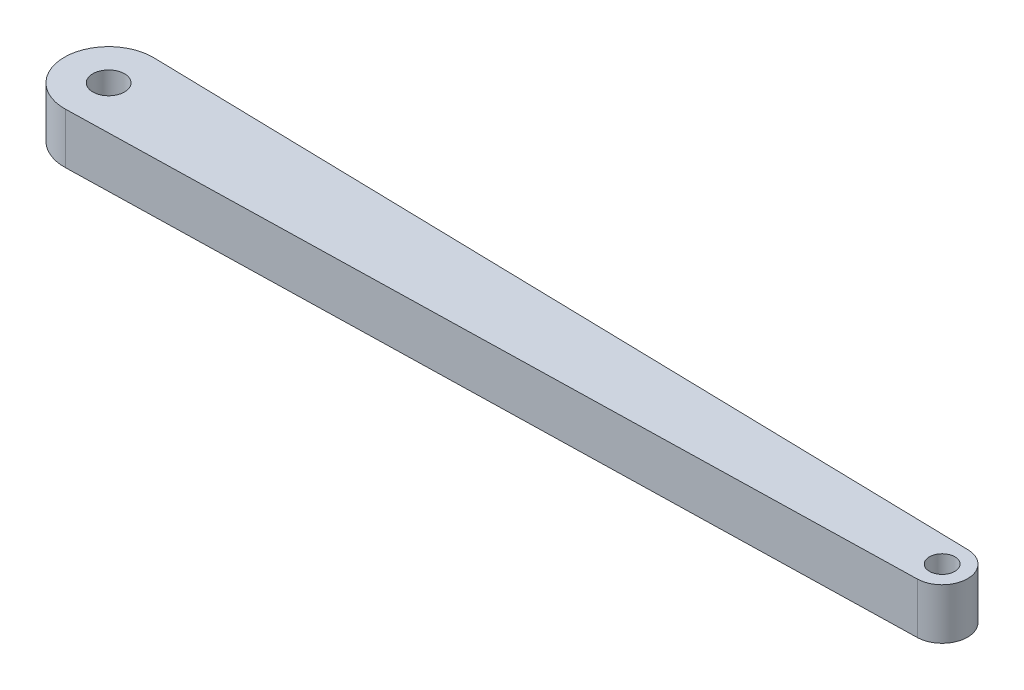
from build123d import *

# Parameters (mm, degrees)
SKETCH1_R           = 25
SKETCH1_R_2         = 20
BOSS_EXTRUDE1_DEPTH = 40


with BuildPart() as part:
    # Sketch1 → Boss-Extrude1 (new body, symmetric)
    with BuildSketch(Plane(origin=(0, 0, 0), x_dir=(1, 0, 0), z_dir=(0, 1, 0))):
        with BuildLine():
            Line((1.596958175, 69.981781376), (1315.912547529, 39.989589358))
            ThreePointArc((1315.912547529, 39.989589358), (1355, 0), (1315.912547529, -39.989589358))
            Line((1315.912547529, -39.989589358), (1.596958175, -69.981781376))
            ThreePointArc((1.596958175, -69.981781376), (-70, 0), (1.596958175, 69.981781376))
        make_face()
        Circle(SKETCH1_R, mode=Mode.SUBTRACT)
        with Locations((1315, 0)):
            Circle(SKETCH1_R_2, mode=Mode.SUBTRACT)
    extrude(amount=BOSS_EXTRUDE1_DEPTH, both=True)


solid = part.part
